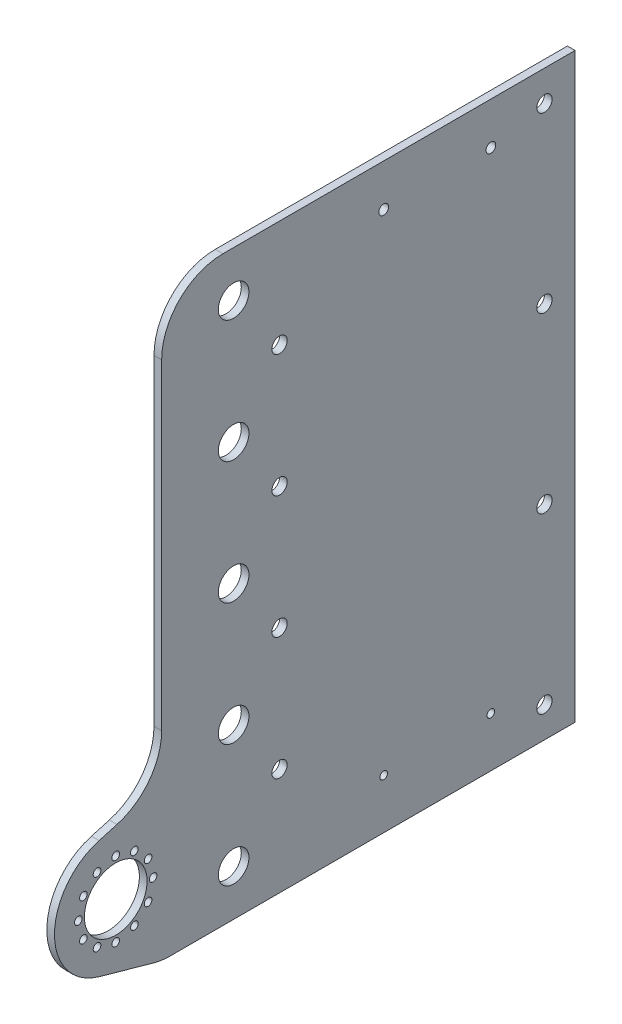
from build123d import *

# Parameters (mm, degrees)
BOSS_EXTRUDE1_DEPTH = 3.175
SKETCH2_R           = 3.175
SKETCH2_R_2         = 6.35
SKETCH2_R_3         = 13
SKETCH2_R_4         = 1.5875
SKETCH2_R_5         = 2.032
CUT_EXTRUDE1_DEPTH  = 4.175
FILLET1_R           = 25.4


with BuildPart() as part:
    # Sketch1 → Boss-Extrude1 (new body)
    with BuildSketch(Plane(origin=(0, 0, 0), x_dir=(0, 0, -1), z_dir=(1, 0, 0))):
        with BuildLine():
            Line((-85.725, -120.65), (-111.65780492, -113.349682952))
            ThreePointArc((-111.65780492, -113.349682952), (-130.175, -88.9), (-111.65780492, -64.450317048))
            Line((-111.65780492, -64.450317048), (-85.725, -57.15))
            Line((-85.725, -57.15), (-85.725, 120.65))
            Line((-85.725, 120.65), (85.725, 120.65))
            Line((85.725, 120.65), (85.725, -120.65))
            Line((85.725, -120.65), (-85.725, -120.65))
        make_face()
    extrude(amount=BOSS_EXTRUDE1_DEPTH)

    # Sketch2 → Cut-Extrude1 (cut, through all)
    with BuildSketch(Plane(origin=(3.175, 0, 0), x_dir=(0, 0, -1), z_dir=(1, 0, 0))):
        with Locations((73.025, -107.95)):
            Circle(SKETCH2_R)
        with Locations((73.025, -35.983333333)):
            Circle(SKETCH2_R)
        with Locations((73.025, 35.983333333)):
            Circle(SKETCH2_R)
        with Locations((73.025, 107.95)):
            Circle(SKETCH2_R)
        with Locations((-55.88, -101.6)):
            Circle(SKETCH2_R_2)
        with Locations((-55.88, -50.8)):
            Circle(SKETCH2_R_2)
        with Locations((-55.88, 0)):
            Circle(SKETCH2_R_2)
        with Locations((-55.88, 50.8)):
            Circle(SKETCH2_R_2)
        with Locations((-55.88, 101.6)):
            Circle(SKETCH2_R_2)
        with Locations((-36.83, -76.2)):
            Circle(SKETCH2_R)
        with Locations((-36.83, -25.4)):
            Circle(SKETCH2_R)
        with Locations((-36.83, 25.4)):
            Circle(SKETCH2_R)
        with Locations((-36.83, 76.2)):
            Circle(SKETCH2_R)
        with Locations((-104.775, -88.9)):
            Circle(SKETCH2_R_3)
        with Locations((-104.775, -73.4)):
            Circle(SKETCH2_R_4)
        with Locations((-97.025, -75.476606241)):
            Circle(SKETCH2_R_4)
        with Locations((-91.351606241, -81.15)):
            Circle(SKETCH2_R_4)
        with Locations((-89.275, -88.9)):
            Circle(SKETCH2_R_4)
        with Locations((-91.351606241, -96.65)):
            Circle(SKETCH2_R_4)
        with Locations((-97.025, -102.323393759)):
            Circle(SKETCH2_R_4)
        with Locations((-104.775, -104.4)):
            Circle(SKETCH2_R_4)
        with Locations((-112.525, -102.323393759)):
            Circle(SKETCH2_R_4)
        with Locations((-118.198393759, -96.65)):
            Circle(SKETCH2_R_4)
        with Locations((-120.275, -88.9)):
            Circle(SKETCH2_R_4)
        with Locations((-118.198393759, -81.15)):
            Circle(SKETCH2_R_4)
        with Locations((-112.525, -75.476606241)):
            Circle(SKETCH2_R_4)
        with Locations((6.35, 103.1875)):
            Circle(SKETCH2_R_5)
        with Locations((50.8, 103.1875)):
            Circle(SKETCH2_R_5)
        with Locations((50.8, -100.0125)):
            Circle(SKETCH2_R_4)
        with Locations((6.35, -100.0125)):
            Circle(SKETCH2_R_4)
    extrude(amount=-CUT_EXTRUDE1_DEPTH, mode=Mode.SUBTRACT)

    # Fillet1
    fillet1_edges = [part.edges().sort_by_distance(p)[0] for p in [
        (1.5875, -120.65, 85.725),
        (1.5875, -57.15, 85.725),
        (1.5875, 120.65, 85.725),
    ]]
    fillet(fillet1_edges, radius=FILLET1_R)


solid = part.part
